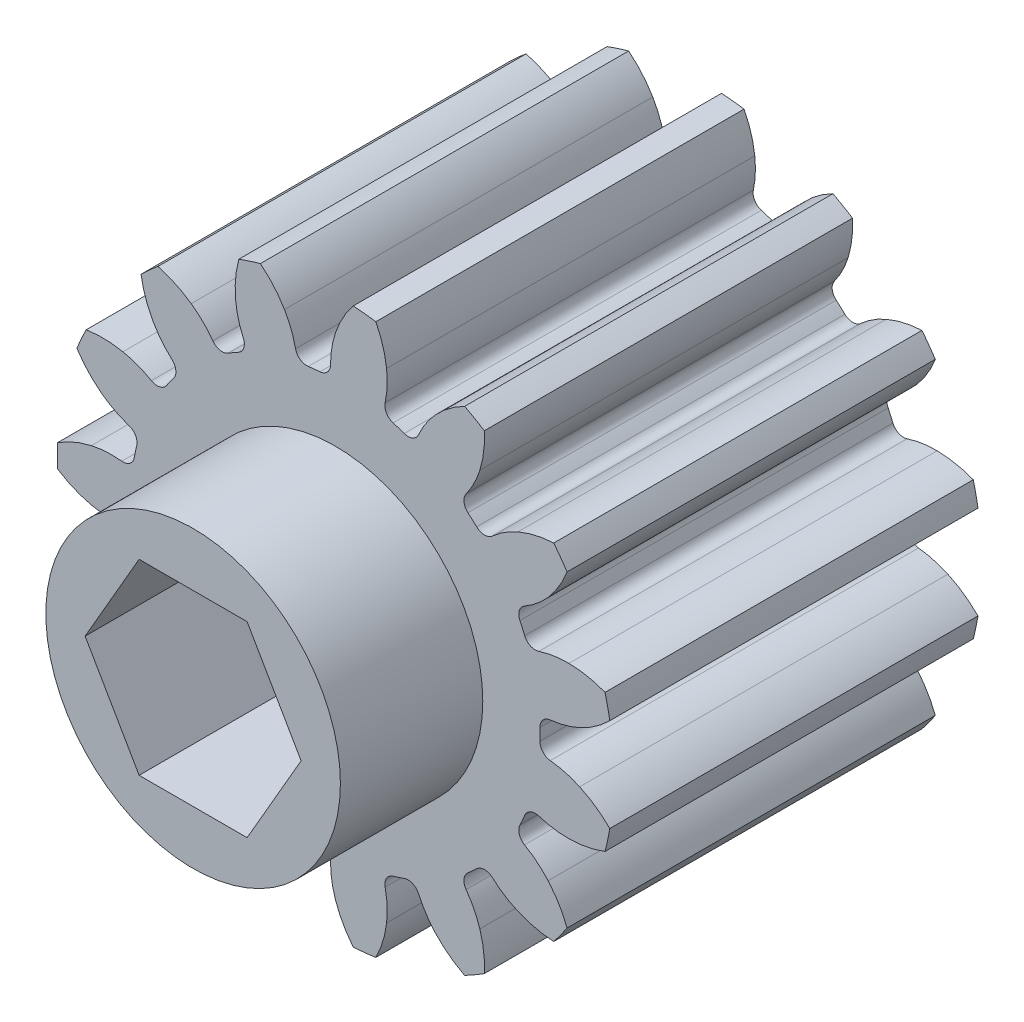
from build123d import *

# Parameters (mm, degrees)
SKETCH1_R            = 7.196666667
ROUND_STOCK_DEPTH    = 4.7625
SINGLE_TOOTH_DEPTH   = 14.939499533
TOOTH_PATTERN_COUNT  = 15
SKETCH4_R            = 3.81
TOPBEARINGBOSS_DEPTH = 3.683
ROUNDBORE_DEPTH      = 14.21738344
ROUNDBORE_DEPTH_BACK = 14.21738344
SKETCH5_R            = 2.41935
HEX_2_DEPTH          = 14.21738344
HEX_2_DEPTH_BACK     = 14.21738344


with BuildPart() as part:
    # Sketch1 → Round Stock (new, symmetric)
    with BuildSketch(Plane.XY):
        Circle(SKETCH1_R)
    extrude(amount=ROUND_STOCK_DEPTH, both=True)

    # Sketch2 → Single Tooth (cut, through all)
    with BuildSketch(Plane.XY.offset(4.7625)):
        with BuildLine():
            ThreePointArc((-6.68842664, -2.656493967), (-7.039402233, -1.496271135), (-7.190675214, -0.293600202))
            ThreePointArc((-7.190675214, -0.293600202), (-6.769612211, -0.518778621), (-6.315077167, -0.665056667))
            ThreePointArc((-6.315077167, -0.665056667), (-5.923784873, -0.719884978), (-5.528796647, -0.709879736))
            ThreePointArc((-5.528796647, -0.709879736), (-5.319713161, -0.76702948), (-5.20546795, -0.951230536))
            ThreePointArc((-5.20546795, -0.951230536), (-5.176031054, -1.100199364), (-5.142331916, -1.248262225))
            ThreePointArc((-5.142331916, -1.248262225), (-5.17177879, -1.463005976), (-5.339541164, -1.60025678))
            ThreePointArc((-5.339541164, -1.60025678), (-5.704450362, -1.751772721), (-6.039612977, -1.961013791))
            ThreePointArc((-6.039612977, -1.961013791), (-6.39535476, -2.279521493), (-6.68842664, -2.656493967))
        make_face()
    single_tooth = extrude(amount=-SINGLE_TOOTH_DEPTH, mode=Mode.SUBTRACT)

    # Tooth Pattern: Single Tooth ×15 about axis
    tooth_pattern_axis = Axis((0, 0, 50), (0, 0, -1))
    for i in range(1, TOOTH_PATTERN_COUNT):
        add(single_tooth.rotate(tooth_pattern_axis, i * 360 / TOOTH_PATTERN_COUNT), mode=Mode.SUBTRACT)

    # Sketch4 → TopBearingBoss (add)
    with BuildSketch(Plane.XY.offset(4.7625)):
        Circle(SKETCH4_R)
    extrude(amount=TOPBEARINGBOSS_DEPTH)

    # Sketch5 → RoundBore (cut, two sides: drawn at the far end of the back side and taken through both)
    with BuildSketch(Plane.XY.offset(-ROUNDBORE_DEPTH_BACK)):
        Circle(SKETCH5_R)
    extrude(amount=ROUNDBORE_DEPTH + ROUNDBORE_DEPTH_BACK, mode=Mode.SUBTRACT)

    # Sketch6 → Hex 2 (cut, two sides: drawn at the far end of the back side and taken through both)
    with BuildSketch(Plane.XY.offset(-HEX_2_DEPTH_BACK)):
        Polygon((1.396812374, 2.41935), (-1.396812374, 2.41935), (-2.793624748, 0), (-1.396812374, -2.41935), (1.396812374, -2.41935), (2.793624748, 0), align=None)
    extrude(amount=HEX_2_DEPTH + HEX_2_DEPTH_BACK, mode=Mode.SUBTRACT)


solid = part.part
